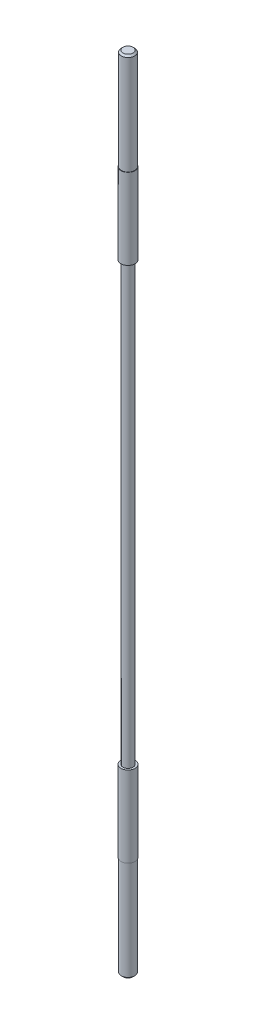
from build123d import *

# Parameters (mm, degrees)
FASE1_SIZE = 0.5


with BuildPart() as part:
    # Skizze1 → Rotation1 (revolve)
    with BuildSketch(Plane(origin=(0, 0, 0), x_dir=(0, 0, -1), z_dir=(1, 0, 0))):
        Polygon((0, 0), (-2, 0), (-2, -30), (-2.1, -30), (-2.1, -54), (-1.5, -54), (-1.5, -184), (-2.1, -184), (-2.1, -208), (-2, -208), (-2, -238), (0, -238), align=None)
    revolve(axis=Axis((0, 0, 0), (0, 1, 0)))

    # Fase1
    fase1_edges = [part.edges().sort_by_distance(p)[0] for p in [
        (0, 0, -2),
        (0, -238, -2),
    ]]
    chamfer(fase1_edges, length=FASE1_SIZE)


solid = part.part
